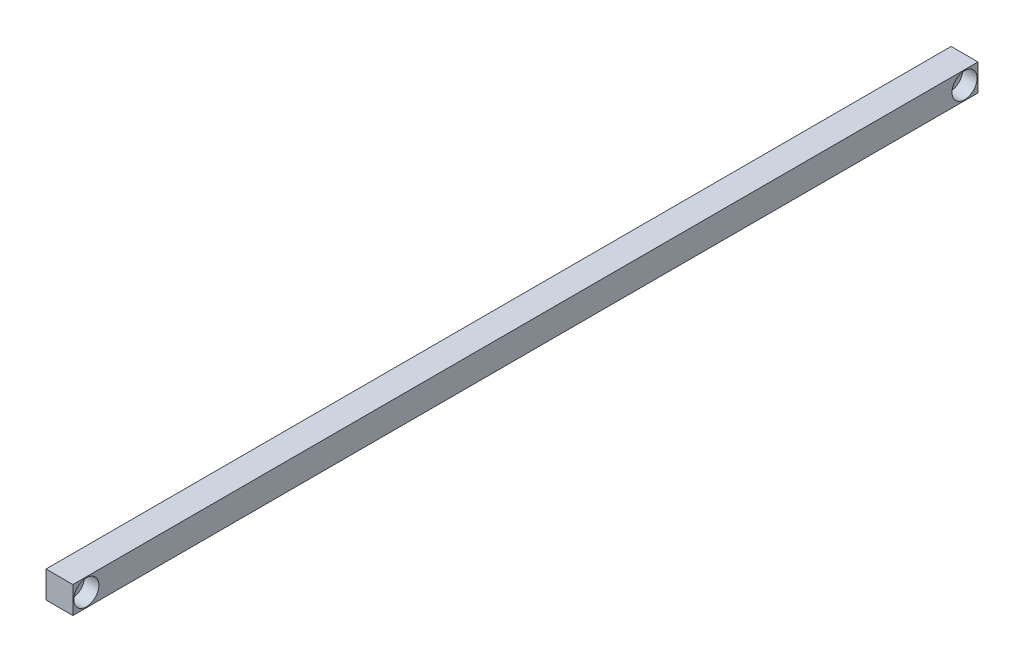
from build123d import *

# Parameters (mm, degrees)
IZIM1_W                     = 15
IZIM1_H                     = 15
Y_KSEKLIK_EKSTR_ZYON1_DEPTH = 252.5
DELIK2_D                    = 8.5
DELIK2_DEPTH                = 15
DELIK2_CBORE_D              = 14
DELIK2_CBORE_DEPTH          = 8


with BuildPart() as part:
    # Çizim1 → Yükseklik-Ekstrüzyon1 (new body, symmetric)
    with BuildSketch(Plane.XY):
        Rectangle(IZIM1_W, IZIM1_H)
    extrude(amount=Y_KSEKLIK_EKSTR_ZYON1_DEPTH, both=True)

    # Delik2
    with Locations(Plane(origin=(7.5, 0, 0), x_dir=(0, 0, -1), z_dir=(1, 0, 0))):
        with Locations((245, 0)):
            delik2 = CounterBoreHole(DELIK2_D / 2, DELIK2_CBORE_D / 2, DELIK2_CBORE_DEPTH, depth=DELIK2_DEPTH)

    # Aynalama1: Delik2 across plane
    add(delik2.mirror(Plane.XY), mode=Mode.SUBTRACT)


solid = part.part
